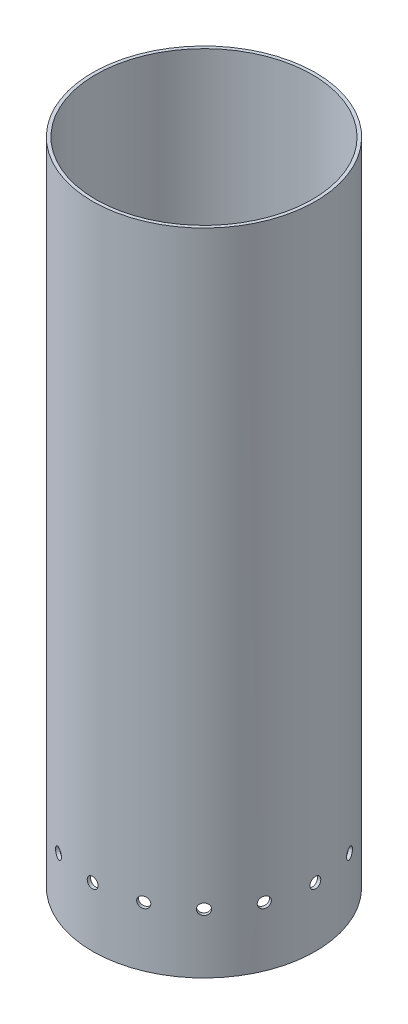
from build123d import *

# Parameters (mm, degrees)
SKETCH1_R           = 65.405
SKETCH1_R_2         = 63.5
BOSS_EXTRUDE1_DEPTH = 381
CUT_EXTRUDE3_REACH  = 410.105
SKETCH4_R           = 3.175
CIRPATTERN2_COUNT   = 16


with BuildPart() as part:
    # Sketch1 → Boss-Extrude1 (new body)
    with BuildSketch(Plane(origin=(0, 0, 0), x_dir=(1, 0, 0), z_dir=(0, 1, 0))):
        Circle(SKETCH1_R)
        Circle(SKETCH1_R_2, mode=Mode.SUBTRACT)
    extrude(amount=-BOSS_EXTRUDE1_DEPTH)

    # Sketch4 → Cut-Extrude3 (cut, up to next)
    with BuildSketch(Plane.XY.offset(65.405), mode=Mode.PRIVATE) as cut_extrude3_sk1:
        with Locations((0, -346.075)):
            Circle(SKETCH4_R)
    cut_extrude3_tool1 = extrude(cut_extrude3_sk1.sketch, amount=-CUT_EXTRUDE3_REACH, mode=Mode.PRIVATE) & part.part
    cut_extrude3 = cut_extrude3_tool1.solids().sort_by_distance((0, -346.075, 65.405))[0]
    add(cut_extrude3, mode=Mode.SUBTRACT)

    # CirPattern2: Cut-Extrude3 ×16 about axis
    cirpattern2_axis = Axis((0, -381, 0), (0, 1, 0))
    for i in range(1, CIRPATTERN2_COUNT):
        add(cut_extrude3.rotate(cirpattern2_axis, i * 360 / CIRPATTERN2_COUNT), mode=Mode.SUBTRACT)


solid = part.part
